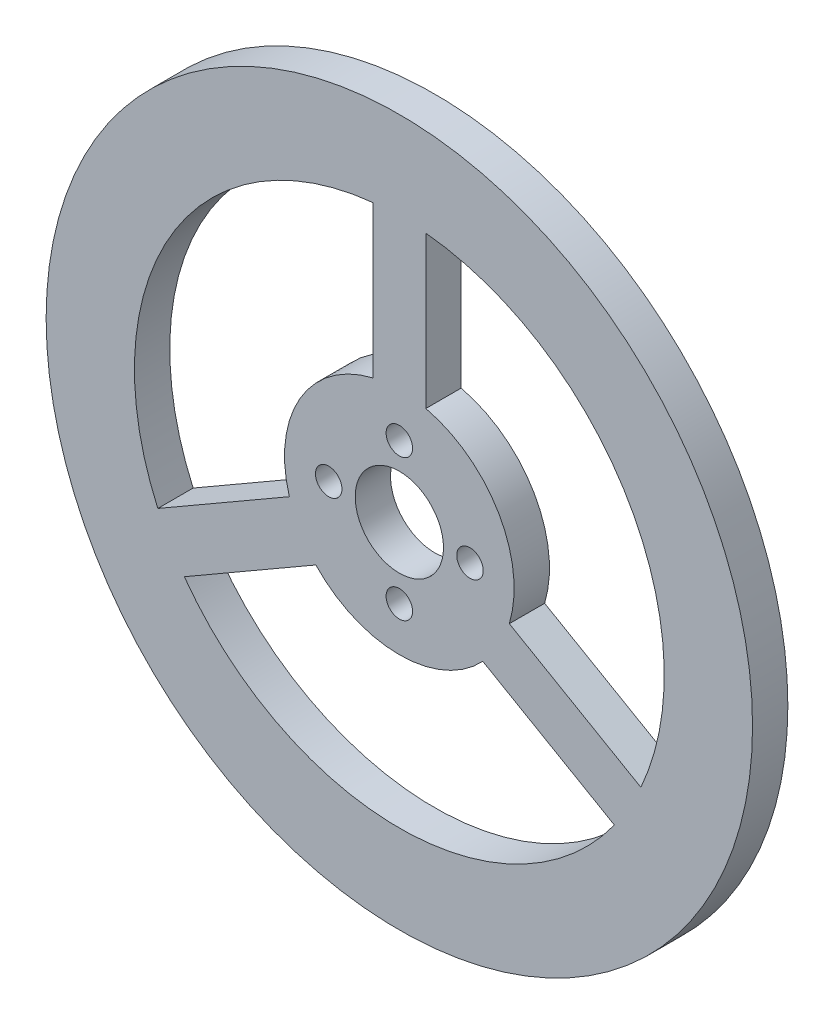
from build123d import *

# Parameters (mm, degrees)
SKETCH_1_R          = 40
EXTRUDE_1_DEPTH     = 4
SKETCH_2_R          = 5
SKETCH_2_R_2        = 1.5
CUT_EXTRUDE_1_DEPTH = 5


with BuildPart() as part:
    # 草图1 → 凸台-拉伸1 (new body)
    with BuildSketch(Plane.XY):
        Circle(SKETCH_1_R)
    extrude(amount=EXTRUDE_1_DEPTH)

    # 草图2 → 切除-拉伸1 (cut, through all)
    with BuildSketch(Plane.XY.offset(4)):
        Circle(SKETCH_2_R)
        with Locations((-8, 0)):
            Circle(SKETCH_2_R_2)
        with Locations((0, 8)):
            Circle(SKETCH_2_R_2)
        with Locations((8, 0)):
            Circle(SKETCH_2_R_2)
        with Locations((0, -8)):
            Circle(SKETCH_2_R_2)
        with BuildLine():
            Line((-3, 29.849623113), (-3, 12.649110641))
            ThreePointArc((-3, 12.649110641), (-11.258330249, 6.5), (-12.45445115, -3.726479109))
            Line((-12.45445115, -3.726479109), (-27.350531909, -12.326735345))
            ThreePointArc((-27.350531909, -12.326735345), (-25.980762114, 15), (-3, 29.849623113))
        make_face()
        with BuildLine():
            Line((3, 29.849623113), (3, 12.649110641))
            ThreePointArc((3, 12.649110641), (11.258330249, 6.5), (12.45445115, -3.726479109))
            Line((12.45445115, -3.726479109), (27.350531909, -12.326735345))
            ThreePointArc((27.350531909, -12.326735345), (25.980762114, 15), (3, 29.849623113))
        make_face()
        with BuildLine():
            Line((24.350531909, -17.522887768), (9.45445115, -8.922631532))
            ThreePointArc((9.45445115, -8.922631532), (0, -13), (-9.45445115, -8.922631532))
            Line((-9.45445115, -8.922631532), (-24.350531909, -17.522887768))
            ThreePointArc((-24.350531909, -17.522887768), (0, -30), (24.350531909, -17.522887768))
        make_face()
    extrude(amount=-CUT_EXTRUDE_1_DEPTH, mode=Mode.SUBTRACT)


solid = part.part
